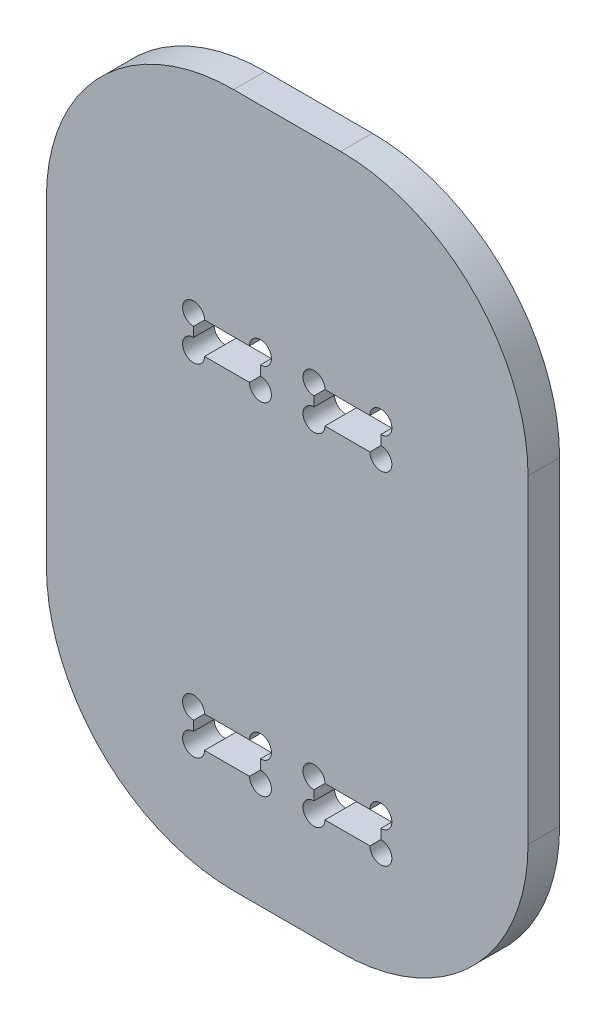
from build123d import *

# Parameters (mm, degrees)
SKETCH1_W           = 90
SKETCH1_H           = 154.65
SKETCH1_W_2         = 12.5
SKETCH1_H_2         = 5.9
BOSS_EXTRUDE1_DEPTH = 5.9
FILLET2_R           = 10
BOSS_EXTRUDE2_DEPTH = 5.9
CUT_EXTRUDE1_REACH  = 7.9
SKETCH5_R           = 2.05
CUT_EXTRUDE4_REACH  = 7.9
FILLET3_R           = 35


with BuildPart() as part:
    # Sketch1 → Boss-Extrude1 (new body)
    with BuildSketch(Plane.XY):
        Rectangle(SKETCH1_W, SKETCH1_H)
        with Locations((-11.25, 14.375)):
            Rectangle(SKETCH1_W_2, SKETCH1_H_2, mode=Mode.SUBTRACT)
        with Locations((11.25, 14.375)):
            Rectangle(SKETCH1_W_2, SKETCH1_H_2, mode=Mode.SUBTRACT)
        with Locations((11.25, -49.375)):
            Rectangle(SKETCH1_W_2, SKETCH1_H_2, mode=Mode.SUBTRACT)
        with Locations((-11.25, -49.375)):
            Rectangle(SKETCH1_W_2, SKETCH1_H_2, mode=Mode.SUBTRACT)
    extrude(amount=BOSS_EXTRUDE1_DEPTH)

    # Fillet2
    fillet2_edges = [part.edges().sort_by_distance(p)[0] for p in [
        (45, -77.325, 2.95),
        (-45, -77.325, 2.95),
        (-45, 77.325, 2.95),
        (45, 77.325, 2.95),
    ]]
    fillet(fillet2_edges, radius=FILLET2_R)

    # Sketch2 → Boss-Extrude2 (add)
    with BuildSketch(Plane.XY.offset(5.9)):
        Polygon((24.6, -77.325), (-24.6, -77.325), (-10, -90.939292058), (-10, -103.239292058), (-4.5, -119.325), (4.5, -119.325), (10, -103.239292058), (10, -90.939292058), align=None)
        with BuildLine():
            Line((-45, 67.325), (-45, 53.482347581))
            Line((-45, 53.482347581), (0, 77.325))
            ThreePointArc((0, 77.325), (-4.9039074, 78.609973195), (-8.547536888, 82.134661558))
            Line((-8.547536888, 82.134661558), (-15.653395136, 93.836708769))
            Line((-15.653395136, 93.836708769), (-36.605205168, 117.74389141))
            Line((-36.605205168, 117.74389141), (-44.297988367, 113.072586812))
            Line((-44.297988367, 113.072586812), (-38.587949383, 93.072586812))
            Line((-38.587949383, 93.072586812), (-31.970396029, 80.241759725))
            ThreePointArc((-31.970396029, 80.241759725), (-32.040056415, 78.284211705), (-33.747908787, 77.325))
            Line((-33.747908787, 77.325), (-35, 77.325))
            ThreePointArc((-35, 77.325), (-42.071067812, 74.396067812), (-45, 67.325))
        make_face()
        with BuildLine():
            ThreePointArc((8.547536888, 82.134661558), (4.9039074, 78.609973195), (0, 77.325))
            Line((0, 77.325), (45, 53.482347581))
            Line((45, 53.482347581), (45, 67.325))
            ThreePointArc((45, 67.325), (42.071067812, 74.396067812), (35, 77.325))
            Line((35, 77.325), (33.747908787, 77.325))
            ThreePointArc((33.747908787, 77.325), (32.040056415, 78.284211705), (31.970396029, 80.241759725))
            Line((31.970396029, 80.241759725), (38.587949383, 93.072586812))
            Line((38.587949383, 93.072586812), (44.297988367, 113.072586812))
            Line((44.297988367, 113.072586812), (36.605205168, 117.74389141))
            Line((36.605205168, 117.74389141), (15.653395136, 93.836708769))
            Line((15.653395136, 93.836708769), (8.547536888, 82.134661558))
        make_face()
    extrude(amount=-BOSS_EXTRUDE2_DEPTH)

    # Sketch5 → Cut-Extrude1 (cut, up to next)
    with BuildSketch(Plane.XY.offset(5.9), mode=Mode.PRIVATE) as cut_extrude1_sk1:
        with Locations((-17.5, 11.425)):
            Circle(SKETCH5_R)
    cut_extrude1_tool1 = extrude(cut_extrude1_sk1.sketch, amount=-CUT_EXTRUDE1_REACH, mode=Mode.PRIVATE) & part.part
    add(cut_extrude1_tool1.solids().sort_by_distance((-17.5, 11.425, 5.9))[0], mode=Mode.SUBTRACT)
    # Sketch5 → Cut-Extrude1 (cut, up to next)
    with BuildSketch(Plane.XY.offset(5.9), mode=Mode.PRIVATE) as cut_extrude1_sk2:
        with Locations((-5, 11.425)):
            Circle(SKETCH5_R)
    cut_extrude1_tool2 = extrude(cut_extrude1_sk2.sketch, amount=-CUT_EXTRUDE1_REACH, mode=Mode.PRIVATE) & part.part
    add(cut_extrude1_tool2.solids().sort_by_distance((-5, 11.425, 5.9))[0], mode=Mode.SUBTRACT)
    # Sketch5 → Cut-Extrude1 (cut, up to next)
    with BuildSketch(Plane.XY.offset(5.9), mode=Mode.PRIVATE) as cut_extrude1_sk3:
        with Locations((-5, 17.325)):
            Circle(SKETCH5_R)
    cut_extrude1_tool3 = extrude(cut_extrude1_sk3.sketch, amount=-CUT_EXTRUDE1_REACH, mode=Mode.PRIVATE) & part.part
    add(cut_extrude1_tool3.solids().sort_by_distance((-5, 17.325, 5.9))[0], mode=Mode.SUBTRACT)
    # Sketch5 → Cut-Extrude1 (cut, up to next)
    with BuildSketch(Plane.XY.offset(5.9), mode=Mode.PRIVATE) as cut_extrude1_sk4:
        with Locations((-17.5, 17.325)):
            Circle(SKETCH5_R)
    cut_extrude1_tool4 = extrude(cut_extrude1_sk4.sketch, amount=-CUT_EXTRUDE1_REACH, mode=Mode.PRIVATE) & part.part
    add(cut_extrude1_tool4.solids().sort_by_distance((-17.5, 17.325, 5.9))[0], mode=Mode.SUBTRACT)
    # Sketch5 → Cut-Extrude1 (cut, up to next)
    with BuildSketch(Plane.XY.offset(5.9), mode=Mode.PRIVATE) as cut_extrude1_sk5:
        with Locations((17.5, 11.425)):
            Circle(SKETCH5_R)
    cut_extrude1_tool5 = extrude(cut_extrude1_sk5.sketch, amount=-CUT_EXTRUDE1_REACH, mode=Mode.PRIVATE) & part.part
    add(cut_extrude1_tool5.solids().sort_by_distance((17.5, 11.425, 5.9))[0], mode=Mode.SUBTRACT)
    # Sketch5 → Cut-Extrude1 (cut, up to next)
    with BuildSketch(Plane.XY.offset(5.9), mode=Mode.PRIVATE) as cut_extrude1_sk6:
        with Locations((17.5, 17.325)):
            Circle(SKETCH5_R)
    cut_extrude1_tool6 = extrude(cut_extrude1_sk6.sketch, amount=-CUT_EXTRUDE1_REACH, mode=Mode.PRIVATE) & part.part
    add(cut_extrude1_tool6.solids().sort_by_distance((17.5, 17.325, 5.9))[0], mode=Mode.SUBTRACT)
    # Sketch5 → Cut-Extrude1 (cut, up to next)
    with BuildSketch(Plane.XY.offset(5.9), mode=Mode.PRIVATE) as cut_extrude1_sk7:
        with Locations((5, 17.325)):
            Circle(SKETCH5_R)
    cut_extrude1_tool7 = extrude(cut_extrude1_sk7.sketch, amount=-CUT_EXTRUDE1_REACH, mode=Mode.PRIVATE) & part.part
    add(cut_extrude1_tool7.solids().sort_by_distance((5, 17.325, 5.9))[0], mode=Mode.SUBTRACT)
    # Sketch5 → Cut-Extrude1 (cut, up to next)
    with BuildSketch(Plane.XY.offset(5.9), mode=Mode.PRIVATE) as cut_extrude1_sk8:
        with Locations((5, 11.425)):
            Circle(SKETCH5_R)
    cut_extrude1_tool8 = extrude(cut_extrude1_sk8.sketch, amount=-CUT_EXTRUDE1_REACH, mode=Mode.PRIVATE) & part.part
    add(cut_extrude1_tool8.solids().sort_by_distance((5, 11.425, 5.9))[0], mode=Mode.SUBTRACT)
    # Sketch5 → Cut-Extrude1 (cut, up to next)
    with BuildSketch(Plane.XY.offset(5.9), mode=Mode.PRIVATE) as cut_extrude1_sk9:
        with Locations((5, -52.325)):
            Circle(SKETCH5_R)
    cut_extrude1_tool9 = extrude(cut_extrude1_sk9.sketch, amount=-CUT_EXTRUDE1_REACH, mode=Mode.PRIVATE) & part.part
    add(cut_extrude1_tool9.solids().sort_by_distance((5, -52.325, 5.9))[0], mode=Mode.SUBTRACT)
    # Sketch5 → Cut-Extrude1 (cut, up to next)
    with BuildSketch(Plane.XY.offset(5.9), mode=Mode.PRIVATE) as cut_extrude1_sk10:
        with Locations((17.5, -52.325)):
            Circle(SKETCH5_R)
    cut_extrude1_tool10 = extrude(cut_extrude1_sk10.sketch, amount=-CUT_EXTRUDE1_REACH, mode=Mode.PRIVATE) & part.part
    add(cut_extrude1_tool10.solids().sort_by_distance((17.5, -52.325, 5.9))[0], mode=Mode.SUBTRACT)
    # Sketch5 → Cut-Extrude1 (cut, up to next)
    with BuildSketch(Plane.XY.offset(5.9), mode=Mode.PRIVATE) as cut_extrude1_sk11:
        with Locations((17.5, -46.425)):
            Circle(SKETCH5_R)
    cut_extrude1_tool11 = extrude(cut_extrude1_sk11.sketch, amount=-CUT_EXTRUDE1_REACH, mode=Mode.PRIVATE) & part.part
    add(cut_extrude1_tool11.solids().sort_by_distance((17.5, -46.425, 5.9))[0], mode=Mode.SUBTRACT)
    # Sketch5 → Cut-Extrude1 (cut, up to next)
    with BuildSketch(Plane.XY.offset(5.9), mode=Mode.PRIVATE) as cut_extrude1_sk12:
        with Locations((5, -46.425)):
            Circle(SKETCH5_R)
    cut_extrude1_tool12 = extrude(cut_extrude1_sk12.sketch, amount=-CUT_EXTRUDE1_REACH, mode=Mode.PRIVATE) & part.part
    add(cut_extrude1_tool12.solids().sort_by_distance((5, -46.425, 5.9))[0], mode=Mode.SUBTRACT)
    # Sketch5 → Cut-Extrude1 (cut, up to next)
    with BuildSketch(Plane.XY.offset(5.9), mode=Mode.PRIVATE) as cut_extrude1_sk13:
        with Locations((-5, -46.425)):
            Circle(SKETCH5_R)
    cut_extrude1_tool13 = extrude(cut_extrude1_sk13.sketch, amount=-CUT_EXTRUDE1_REACH, mode=Mode.PRIVATE) & part.part
    add(cut_extrude1_tool13.solids().sort_by_distance((-5, -46.425, 5.9))[0], mode=Mode.SUBTRACT)
    # Sketch5 → Cut-Extrude1 (cut, up to next)
    with BuildSketch(Plane.XY.offset(5.9), mode=Mode.PRIVATE) as cut_extrude1_sk14:
        with Locations((-5, -52.325)):
            Circle(SKETCH5_R)
    cut_extrude1_tool14 = extrude(cut_extrude1_sk14.sketch, amount=-CUT_EXTRUDE1_REACH, mode=Mode.PRIVATE) & part.part
    add(cut_extrude1_tool14.solids().sort_by_distance((-5, -52.325, 5.9))[0], mode=Mode.SUBTRACT)
    # Sketch5 → Cut-Extrude1 (cut, up to next)
    with BuildSketch(Plane.XY.offset(5.9), mode=Mode.PRIVATE) as cut_extrude1_sk15:
        with Locations((-17.5, -52.325)):
            Circle(SKETCH5_R)
    cut_extrude1_tool15 = extrude(cut_extrude1_sk15.sketch, amount=-CUT_EXTRUDE1_REACH, mode=Mode.PRIVATE) & part.part
    add(cut_extrude1_tool15.solids().sort_by_distance((-17.5, -52.325, 5.9))[0], mode=Mode.SUBTRACT)
    # Sketch5 → Cut-Extrude1 (cut, up to next)
    with BuildSketch(Plane.XY.offset(5.9), mode=Mode.PRIVATE) as cut_extrude1_sk16:
        with Locations((-17.5, -46.425)):
            Circle(SKETCH5_R)
    cut_extrude1_tool16 = extrude(cut_extrude1_sk16.sketch, amount=-CUT_EXTRUDE1_REACH, mode=Mode.PRIVATE) & part.part
    add(cut_extrude1_tool16.solids().sort_by_distance((-17.5, -46.425, 5.9))[0], mode=Mode.SUBTRACT)

    # Sketch7 → Cut-Extrude4 (cut, up to next)
    with BuildSketch(Plane.XY.offset(5.9), mode=Mode.PRIVATE) as cut_extrude4_sk1:
        with BuildLine():
            Line((-45, 67.325), (-45, 57.325))
            Line((-45, 57.325), (45, 57.325))
            Line((45, 57.325), (45, 67.325))
            ThreePointArc((45, 67.325), (42.071067812, 74.396067812), (35, 77.325))
            Line((35, 77.325), (33.747908787, 77.325))
            ThreePointArc((33.747908787, 77.325), (32.040056415, 78.284211705), (31.970396029, 80.241759725))
            Line((31.970396029, 80.241759725), (38.587949383, 93.072586812))
            Line((38.587949383, 93.072586812), (44.297988367, 113.072586812))
            Line((44.297988367, 113.072586812), (36.605205168, 117.74389141))
            Line((36.605205168, 117.74389141), (15.653395136, 93.836708769))
            Line((15.653395136, 93.836708769), (8.547536888, 82.134661558))
            ThreePointArc((8.547536888, 82.134661558), (0, 77.325), (-8.547536888, 82.134661558))
            Line((-8.547536888, 82.134661558), (-15.653395136, 93.836708769))
            Line((-15.653395136, 93.836708769), (-36.605205168, 117.74389141))
            Line((-36.605205168, 117.74389141), (-44.297988367, 113.072586812))
            Line((-44.297988367, 113.072586812), (-38.587949383, 93.072586812))
            Line((-38.587949383, 93.072586812), (-31.970396029, 80.241759725))
            ThreePointArc((-31.970396029, 80.241759725), (-32.040056415, 78.284211705), (-33.747908787, 77.325))
            Line((-33.747908787, 77.325), (-35, 77.325))
            ThreePointArc((-35, 77.325), (-42.071067812, 74.396067812), (-45, 67.325))
        make_face()
    cut_extrude4_tool1 = extrude(cut_extrude4_sk1.sketch, amount=-CUT_EXTRUDE4_REACH, mode=Mode.PRIVATE) & part.part
    add(cut_extrude4_tool1.solids().sort_by_distance((-34.373954, 76.241005, 5.9))[0], mode=Mode.SUBTRACT)
    # Sketch7 → Cut-Extrude4 (cut, up to next)
    with BuildSketch(Plane.XY.offset(5.9), mode=Mode.PRIVATE) as cut_extrude4_sk2:
        with BuildLine():
            Line((43.660254038, -72.325), (-43.660254038, -72.325))
            ThreePointArc((-43.660254038, -72.325), (-40, -75.985254038), (-35, -77.325))
            Line((-35, -77.325), (-24.6, -77.325))
            Line((-24.6, -77.325), (-10, -90.939292058))
            Line((-10, -90.939292058), (-10, -103.239292058))
            Line((-10, -103.239292058), (-4.5, -119.325))
            Line((-4.5, -119.325), (4.5, -119.325))
            Line((4.5, -119.325), (10, -103.239292058))
            Line((10, -103.239292058), (10, -90.939292058))
            Line((10, -90.939292058), (24.6, -77.325))
            Line((24.6, -77.325), (35, -77.325))
            ThreePointArc((35, -77.325), (40, -75.985254038), (43.660254038, -72.325))
        make_face()
    cut_extrude4_tool2 = extrude(cut_extrude4_sk2.sketch, amount=-CUT_EXTRUDE4_REACH, mode=Mode.PRIVATE) & part.part
    add(cut_extrude4_tool2.solids().sort_by_distance((0, -87.785653, 5.9))[0], mode=Mode.SUBTRACT)

    # Fillet3
    fillet3_edges = [part.edges().sort_by_distance(p)[0] for p in [
        (43.660254038, -72.325, 2.95),
        (-43.660254038, -72.325, 2.95),
        (45, 57.325, 2.95),
        (-45, 57.325, 2.95),
    ]]
    fillet(fillet3_edges, radius=FILLET3_R)


solid = part.part
